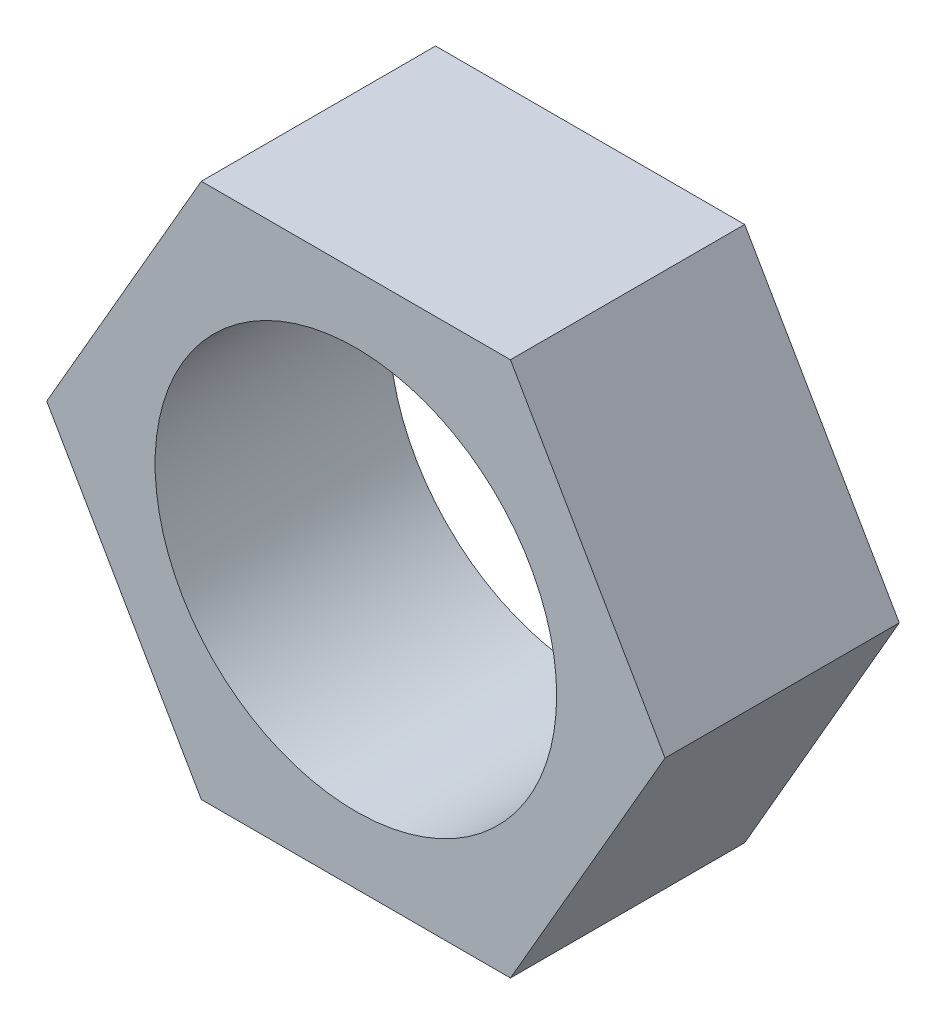
from build123d import *

# Parameters (mm, degrees)
CROQUIS1_R              = 6
SALIENTE_EXTRUIR1_DEPTH = 7


with BuildPart() as part:
    # Croquis1 → Saliente-Extruir1 (new body)
    with BuildSketch(Plane.XY):
        Polygon((9.237604307, 0), (4.618802154, 8), (-4.618802154, 8), (-9.237604307, 0), (-4.618802154, -8), (4.618802154, -8), align=None)
        Circle(CROQUIS1_R, mode=Mode.SUBTRACT)
    extrude(amount=SALIENTE_EXTRUIR1_DEPTH)


solid = part.part
